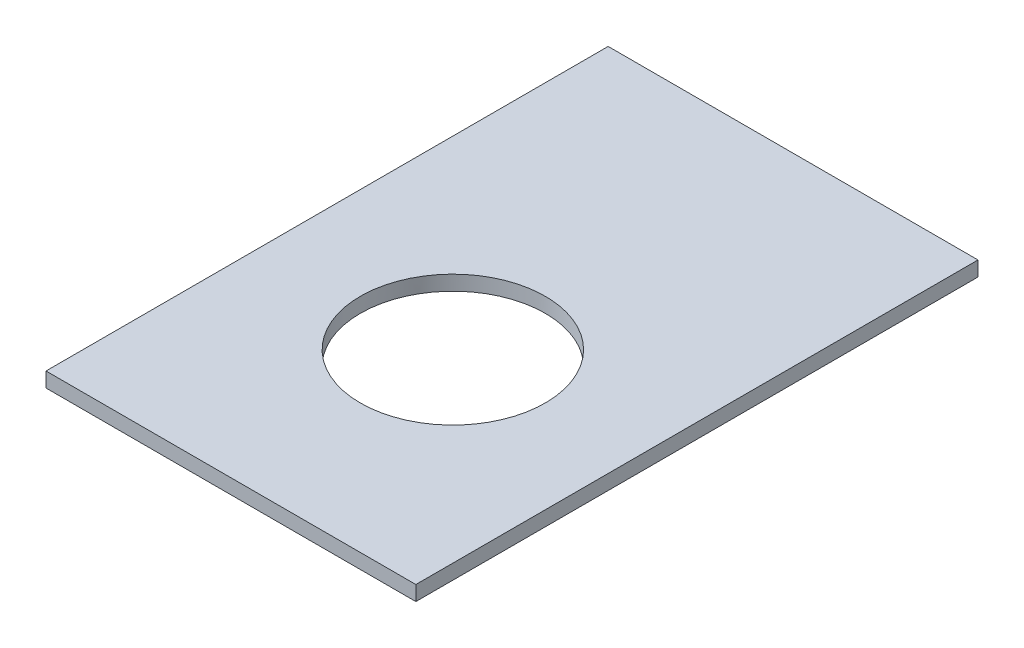
from build123d import *

# Parameters (mm, degrees)
SKETCH1_W           = 500
SKETCH1_H           = 760
BOSS_EXTRUDE1_DEPTH = 20
CUT_EXTRUDE2_REACH  = 22
SKETCH3_R           = 125


with BuildPart() as part:
    # Sketch1 → Boss-Extrude1 (new body)
    with BuildSketch(Plane(origin=(0, 0, 0), x_dir=(1, 0, 0), z_dir=(0, 1, 0))):
        Rectangle(SKETCH1_W, SKETCH1_H)
    extrude(amount=BOSS_EXTRUDE1_DEPTH)

    # Sketch3 → Cut-Extrude2 (cut, up to next)
    with BuildSketch(Plane(origin=(0, 20, 0), x_dir=(1, 0, 0), z_dir=(0, 1, 0)), mode=Mode.PRIVATE) as cut_extrude2_sk1:
        with Locations((0, -80)):
            Circle(SKETCH3_R)
    cut_extrude2_tool1 = extrude(cut_extrude2_sk1.sketch, amount=-CUT_EXTRUDE2_REACH, mode=Mode.PRIVATE) & part.part
    add(cut_extrude2_tool1.solids().sort_by_distance((0, 20, 80))[0], mode=Mode.SUBTRACT)


solid = part.part
